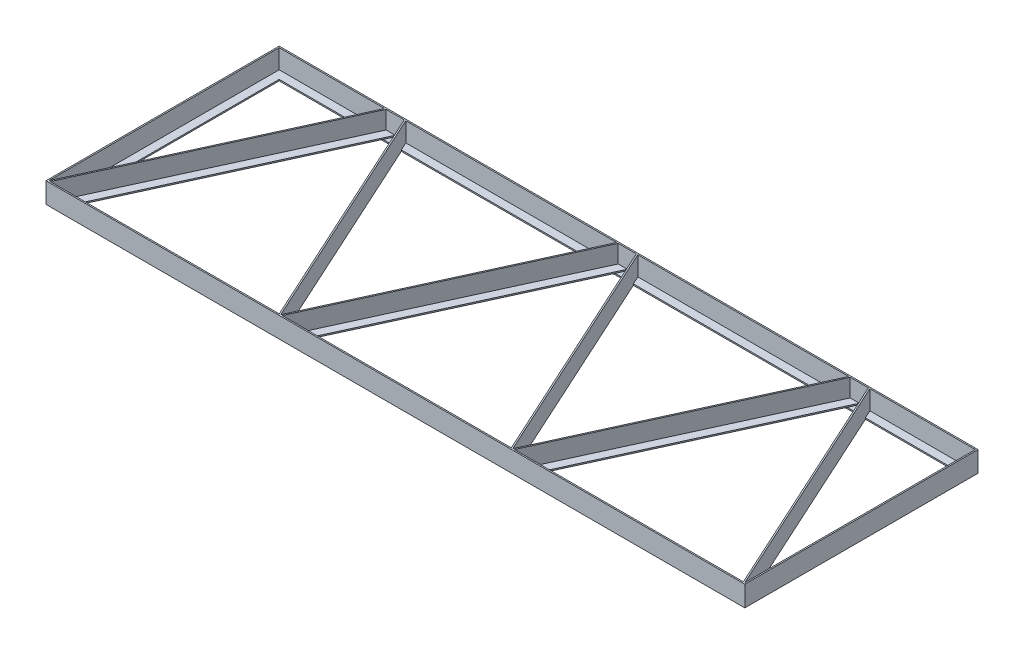
from build123d import *

# Parameters (mm, degrees)
SKETCH1_W            = 1818.96
SKETCH1_H            = 606.96
BOSS_EXTRUDE2_DEPTH  = 53.48
BOSS_EXTRUDE9_DEPTH  = 3.48
BOSS_EXTRUDE10_DEPTH = 6.96
BOSS_EXTRUDE11_START = 6.96
BOSS_EXTRUDE11_DEPTH = 3.48


with BuildPart() as part:
    # Sketch1 → Boss-Extrude2 (new body)
    with BuildSketch(Plane(origin=(0, 0, 0), x_dir=(1, 0, 0), z_dir=(0, 1, 0))):
        with Locations((906, -300)):
            Rectangle(SKETCH1_W, SKETCH1_H)
        Polygon((274.507750304, 0), (0, -600), (0, 0), align=None, mode=Mode.SUBTRACT)
        Polygon((3.826921158, -600), (278.334671461, 0), (325.665328539, 0), (600.173078842, -600), align=None, mode=Mode.SUBTRACT)
        Polygon((607.826921158, -600), (882.334671461, 0), (929.665328539, 0), (1204.173078842, -600), align=None, mode=Mode.SUBTRACT)
        Polygon((1211.826921158, -600), (1486.334671461, 0), (1533.665328539, 0), (1808.173078842, -600), align=None, mode=Mode.SUBTRACT)
        Polygon((1812, 0), (1812, -600), (1537.492249696, 0), align=None, mode=Mode.SUBTRACT)
        Polygon((933.492249696, 0), (1482.507750304, 0), (1208, -600), align=None, mode=Mode.SUBTRACT)
        Polygon((329.492249696, 0), (878.507750304, 0), (604, -600), align=None, mode=Mode.SUBTRACT)
    extrude(amount=BOSS_EXTRUDE2_DEPTH)

    # Sketch1_7 → Boss-Extrude9 (add)
    with BuildSketch(Plane(origin=(0, 0, 0), x_dir=(1, 0, 0), z_dir=(0, 1, 0))):
        Polygon((37.337927674, -578.48), (27.492249696, -600), (576.507750304, -600), (566.662072326, -578.48), align=None)
        Polygon((274.507750304, 0), (0, 0), (0, -600), (21.52, -552.963076686), (21.52, -21.52), (264.662072326, -21.52), align=None)
        Polygon((641.337927674, -578.48), (631.492249696, -600), (1180.507750304, -600), (1170.662072326, -578.48), align=None)
        Polygon((1245.337927674, -578.48), (1235.492249696, -600), (1784.507750304, -600), (1774.662072326, -578.48), align=None)
        Polygon((1812, 0), (1537.492249696, 0), (1547.337927674, -21.52), (1790.48, -21.52), (1790.48, -552.963076686), (1812, -600), align=None)
        Polygon((1198.154322022, -578.48), (1208, -600), (1217.845677978, -578.48), align=None)
        Polygon((594.154322022, -578.48), (604, -600), (613.845677978, -578.48), align=None)
        Polygon((1482.507750304, 0), (933.492249696, 0), (943.337927674, -21.52), (1472.662072326, -21.52), align=None)
        Polygon((1519.845677978, -21.52), (1510, 0), (1500.154322022, -21.52), align=None)
        Polygon((915.845677978, -21.52), (906, 0), (896.154322022, -21.52), align=None)
        Polygon((878.507750304, 0), (329.492249696, 0), (339.337927674, -21.52), (868.662072326, -21.52), align=None)
        Polygon((311.845677978, -21.52), (302, 0), (292.154322022, -21.52), align=None)
    extrude(amount=BOSS_EXTRUDE9_DEPTH)

    # Sketch1_9 → Boss-Extrude10 (add)
    with BuildSketch(Plane(origin=(0, 0, 0), x_dir=(1, 0, 0), z_dir=(0, 1, 0))):
        Polygon((1774.662072326, -578.48), (1784.507750304, -600), (1808.173078842, -600), (1790.48, -561.327695507), (1790.48, -578.48), align=None)
        Polygon((1221.672599135, -578.48), (1211.826921158, -600), (1235.492249696, -600), (1245.337927674, -578.48), align=None)
        Polygon((1170.662072326, -578.48), (1180.507750304, -600), (1204.173078842, -600), (1194.327400865, -578.48), align=None)
        Polygon((617.672599135, -578.48), (607.826921158, -600), (631.492249696, -600), (641.337927674, -578.48), align=None)
        Polygon((566.662072326, -578.48), (576.507750304, -600), (600.173078842, -600), (590.327400865, -578.48), align=None)
        Polygon((21.52, -561.327695507), (3.826921158, -600), (27.492249696, -600), (37.337927674, -578.48), (21.52, -578.48), align=None)
        Polygon((302, 0), (278.334671461, 0), (268.488993484, -21.52), (292.154322022, -21.52), align=None)
        Polygon((325.665328539, 0), (302, 0), (311.845677978, -21.52), (335.511006516, -21.52), align=None)
        Polygon((929.665328539, 0), (906, 0), (915.845677978, -21.52), (939.511006516, -21.52), align=None)
        Polygon((906, 0), (882.334671461, 0), (872.488993484, -21.52), (896.154322022, -21.52), align=None)
        Polygon((1533.665328539, 0), (1510, 0), (1519.845677978, -21.52), (1543.511006516, -21.52), align=None)
        Polygon((1510, 0), (1486.334671461, 0), (1476.488993484, -21.52), (1500.154322022, -21.52), align=None)
    extrude(amount=BOSS_EXTRUDE10_DEPTH)

    # Sketch1_10 → Boss-Extrude11 (add)
    with BuildSketch(Plane(origin=(0, 0, 0), x_dir=(1, 0, 0), z_dir=(0, 1, 0)).offset(BOSS_EXTRUDE11_START)):
        Polygon((292.154322022, -21.52), (268.488993484, -21.52), (21.52, -561.327695507), (21.52, -578.48), (37.337927674, -578.48), align=None)
        Polygon((335.511006516, -21.52), (311.845677978, -21.52), (566.662072326, -578.48), (590.327400865, -578.48), align=None)
        Polygon((896.154322022, -21.52), (872.488993484, -21.52), (617.672599135, -578.48), (641.337927674, -578.48), align=None)
        Polygon((939.511006516, -21.52), (915.845677978, -21.52), (1170.662072326, -578.48), (1194.327400865, -578.48), align=None)
        Polygon((1500.154322022, -21.52), (1476.488993484, -21.52), (1221.672599135, -578.48), (1245.337927674, -578.48), align=None)
        Polygon((1543.511006516, -21.52), (1519.845677978, -21.52), (1774.662072326, -578.48), (1790.48, -578.48), (1790.48, -561.327695507), align=None)
    extrude(amount=-BOSS_EXTRUDE11_DEPTH)


solid = part.part
